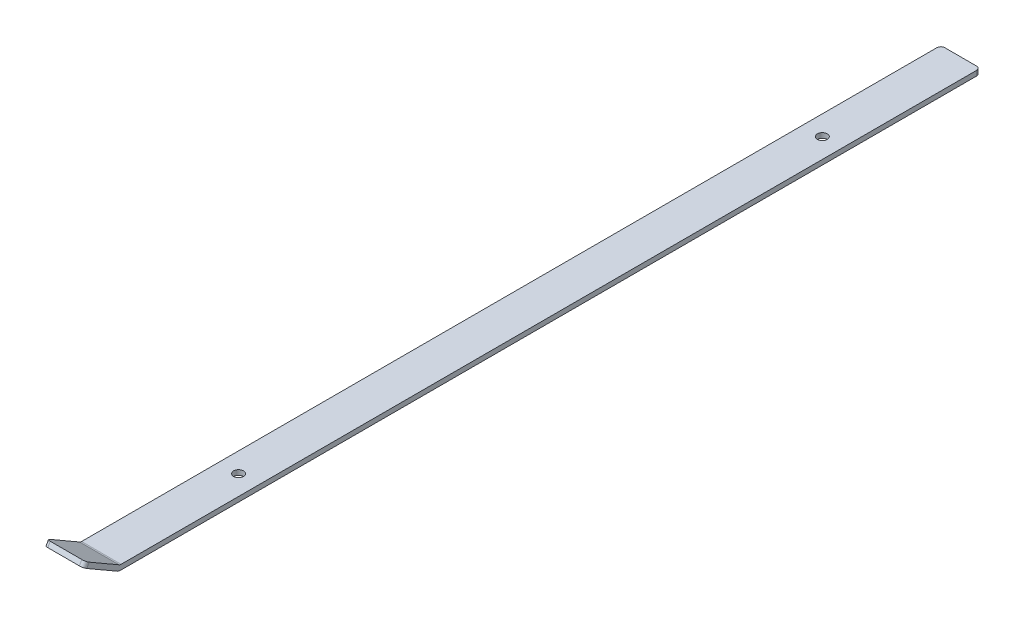
from build123d import *

# Parameters (mm, degrees)
BOSS_EXTRUDE1_DEPTH = 25.4
SKETCH2_R           = 3.175
CUT_EXTRUDE1_DEPTH  = 4.175
FILLET1_R           = 2.54


with BuildPart() as part:
    # Sketch1 → Boss-Extrude1 (new body)
    with BuildSketch(Plane(origin=(0, 0, 0), x_dir=(0, 0, -1), z_dir=(1, 0, 0))):
        with BuildLine():
            Line((0, 0), (-21.997045256, 12.7))
            Line((-21.997045256, 12.7), (-23.584545256, 9.950369343))
            Line((-23.584545256, 9.950369343), (-1.5875, -2.749630657))
            ThreePointArc((-1.5875, -2.749630657), (-0.821750468, -3.066814498), (0, -3.175))
            Line((0, -3.175), (553.1612, -3.175))
            Line((553.1612, -3.175), (553.1612, 0))
            Line((553.1612, 0), (0, 0))
        make_face()
    extrude(amount=BOSS_EXTRUDE1_DEPTH)

    # Sketch2 → Cut-Extrude1 (cut, through all)
    with BuildSketch(Plane(origin=(0, 0, 0), x_dir=(1, 0, 0), z_dir=(0, 1, 0))):
        with Locations((12.7, 88.9)):
            Circle(SKETCH2_R)
        with Locations((12.7, 464.2612)):
            Circle(SKETCH2_R)
    extrude(amount=-CUT_EXTRUDE1_DEPTH, mode=Mode.SUBTRACT)

    # Fillet1
    fillet1_edges = [part.edges().sort_by_distance(p)[0] for p in [
        (25.4, 11.325184671, 22.790795256),
        (12.7, 0, 0),
        (25.4, -1.5875, -553.1612),
        (0, -1.5875, -553.1612),
        (0, 11.325184671, 22.790795256),
    ]]
    fillet(fillet1_edges, radius=FILLET1_R)


solid = part.part
